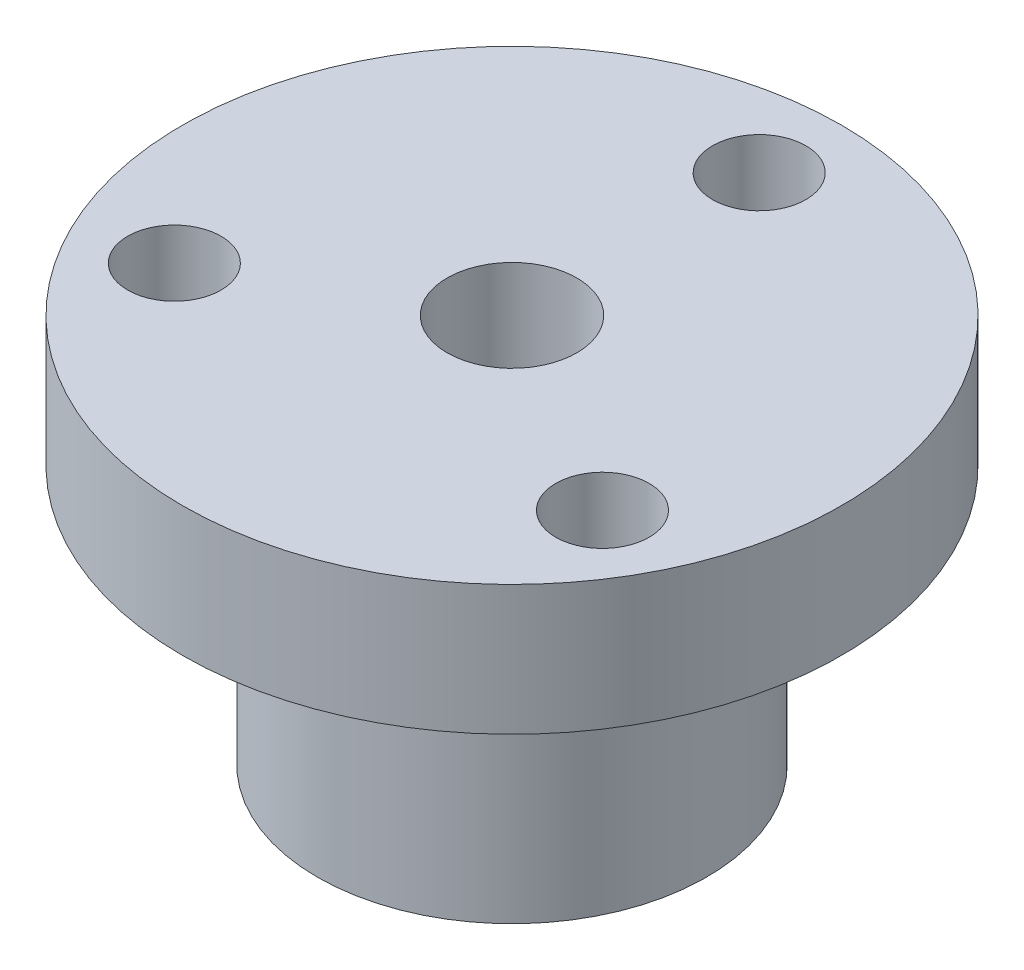
from build123d import *

# Parameters (mm, degrees)
SKETCH1_R           = 7.5
SKETCH1_R_2         = 2.5
BOSS_EXTRUDE1_DEPTH = 10
SKETCH2_R           = 12.7
SKETCH2_R_2         = 2.5
BOSS_EXTRUDE2_DEPTH = 5
SKETCH3_R           = 1.8
CUT_EXTRUDE1_DEPTH  = 16


with BuildPart() as part:
    # Sketch1 → Boss-Extrude1 (new body)
    with BuildSketch(Plane(origin=(0, 0, 0), x_dir=(1, 0, 0), z_dir=(0, 1, 0))):
        Circle(SKETCH1_R)
        Circle(SKETCH1_R_2, mode=Mode.SUBTRACT)
    extrude(amount=BOSS_EXTRUDE1_DEPTH)

    # Sketch2 → Boss-Extrude2 (add)
    with BuildSketch(Plane(origin=(0, 10, 0), x_dir=(-1, 0, 0), z_dir=(0, 1, 0))):
        Circle(SKETCH2_R)
        Circle(SKETCH2_R_2, mode=Mode.SUBTRACT)
    extrude(amount=BOSS_EXTRUDE2_DEPTH)

    # Sketch3 → Cut-Extrude1 (cut, through all)
    with BuildSketch(Plane(origin=(0, 15, 0), x_dir=(-1, 0, 0), z_dir=(0, 1, 0))):
        with Locations((0, -9.525)):
            Circle(SKETCH3_R)
        with Locations((-8.248891971, 4.7625)):
            Circle(SKETCH3_R)
        with Locations((8.248891971, 4.7625)):
            Circle(SKETCH3_R)
    extrude(amount=-CUT_EXTRUDE1_DEPTH, mode=Mode.SUBTRACT)


solid = part.part
